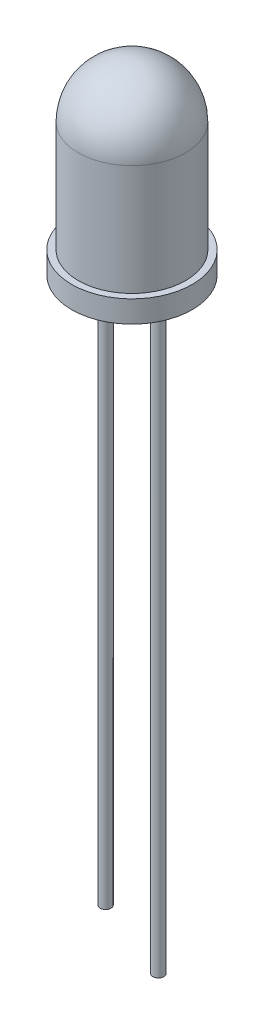
from build123d import *

# Parameters (mm, degrees)
CROQUIS1_R              = 2.75
SALIENTE_EXTRUIR1_DEPTH = 1
CROQUIS2_R              = 2.45
SALIENTE_EXTRUIR2_DEPTH = 5.05
C_PULA1_FACE_RADIUS     = 2.45
C_PULA1_HEIGHT          = 2.45
CROQUIS3_R              = 0.25
SALIENTE_EXTRUIR3_DEPTH = 25.5
CROQUIS5_R              = 0.25
SALIENTE_EXTRUIR5_DEPTH = 27


with BuildPart() as part:
    # Croquis1 → Saliente-Extruir1 (new body)
    with BuildSketch(Plane(origin=(0, 0, 0), x_dir=(1, 0, 0), z_dir=(0, 1, 0))):
        Circle(CROQUIS1_R)
    extrude(amount=SALIENTE_EXTRUIR1_DEPTH)

    # Croquis2 → Saliente-Extruir2 (add)
    with BuildSketch(Plane(origin=(0, 1, 0), x_dir=(1, 0, 0), z_dir=(0, 1, 0))):
        Circle(CROQUIS2_R)
    extrude(amount=SALIENTE_EXTRUIR2_DEPTH)

    # C_pula1: a dome of height H over a round flat face of radius A is a cap of a sphere of radius (A * A + H * H) / (2 * H)
    c_pula1_r = (C_PULA1_FACE_RADIUS * C_PULA1_FACE_RADIUS + C_PULA1_HEIGHT * C_PULA1_HEIGHT) / (2 * C_PULA1_HEIGHT)
    c_pula1_base = Plane((0, 6.05, 0), z_dir=(0, 1, 0))
    with Locations(c_pula1_base.offset(C_PULA1_HEIGHT - c_pula1_r)):
        c_pula1_ball = Sphere(c_pula1_r, mode=Mode.PRIVATE)
    add(split(c_pula1_ball, bisect_by=c_pula1_base, keep=Keep.TOP, mode=Mode.PRIVATE))

    # Croquis3 → Saliente-Extruir3 (add)
    with BuildSketch(Plane.XZ):
        with Locations((-1.205162028, 0)):
            Circle(CROQUIS3_R)
    extrude(amount=SALIENTE_EXTRUIR3_DEPTH)

    # Croquis5 → Saliente-Extruir5 (add)
    with BuildSketch(Plane.XZ):
        with Locations((1.205162028, 0)):
            Circle(CROQUIS5_R)
    extrude(amount=SALIENTE_EXTRUIR5_DEPTH)


solid = part.part
